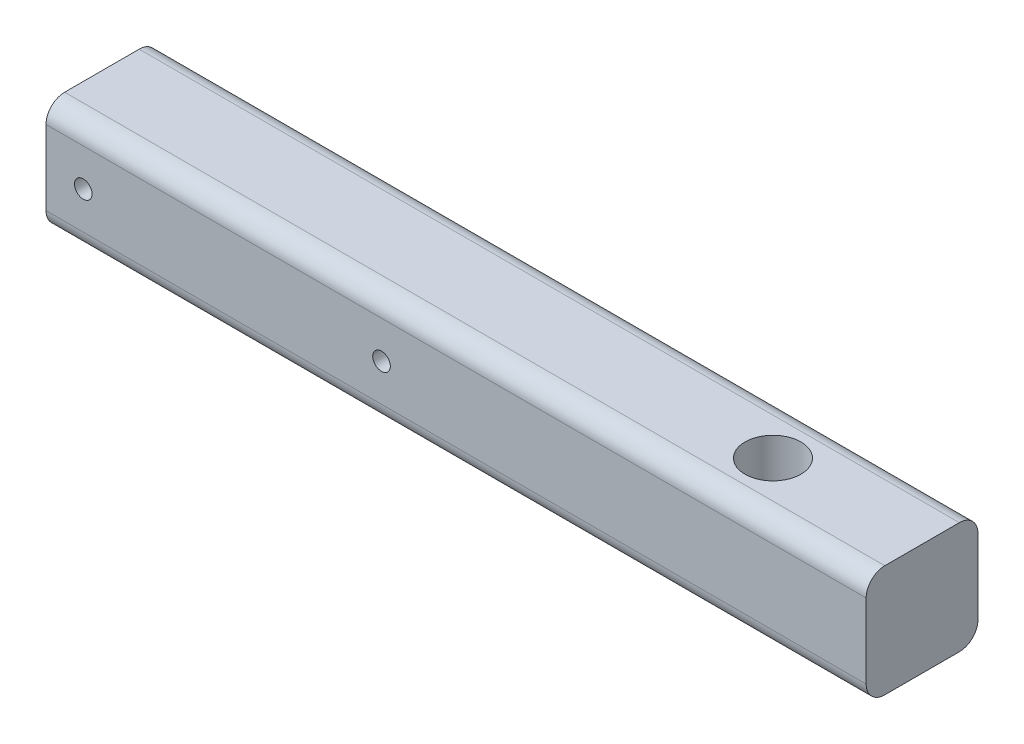
from build123d import *

# Parameters (mm, degrees)
SKETCH1_W           = 19.05
SKETCH1_H           = 19.05
BOSS_EXTRUDE1_DEPTH = 139.7
SKETCH2_R           = 4.7625
CUT_EXTRUDE1_DEPTH  = 20.05
SKETCH3_R           = 1.5
CUT_EXTRUDE2_DEPTH  = 20.05
FILLET1_R           = 3.175


with BuildPart() as part:
    # Sketch1 → Boss-Extrude1 (new body)
    with BuildSketch(Plane(origin=(0, 0, 0), x_dir=(0, 0, -1), z_dir=(1, 0, 0))):
        Rectangle(SKETCH1_W, SKETCH1_H)
    extrude(amount=BOSS_EXTRUDE1_DEPTH)

    # Sketch2 → Cut-Extrude1 (cut, through all)
    with BuildSketch(Plane(origin=(0, 9.525, 0), x_dir=(1, 0, 0), z_dir=(0, 1, 0))):
        with Locations((114.3, 0)):
            Circle(SKETCH2_R)
    extrude(amount=-CUT_EXTRUDE1_DEPTH, mode=Mode.SUBTRACT)

    # Sketch3 → Cut-Extrude2 (cut, through all)
    with BuildSketch(Plane.XY.offset(9.525)):
        with Locations((6.35, 0)):
            Circle(SKETCH3_R)
        with Locations((57.15, 0)):
            Circle(SKETCH3_R)
    extrude(amount=-CUT_EXTRUDE2_DEPTH, mode=Mode.SUBTRACT)

    # Fillet1
    fillet1_edges = [part.edges().sort_by_distance(p)[0] for p in [
        (69.85, -9.525, 9.525),
        (69.85, 9.525, 9.525),
        (69.85, 9.525, -9.525),
        (69.85, -9.525, -9.525),
    ]]
    fillet(fillet1_edges, radius=FILLET1_R)


solid = part.part
